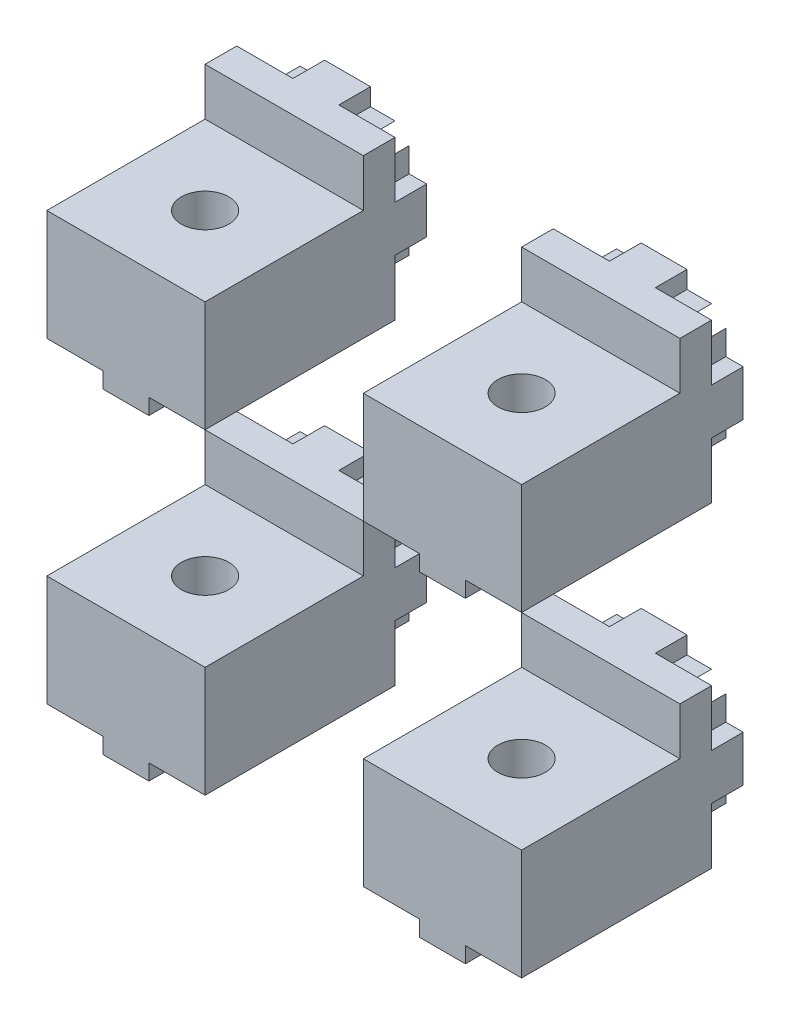
from build123d import *

# Parameters (mm, degrees)
SKETCH1_W                         = 10
SKETCH1_H                         = 10
MAIN_DEPTH                        = 12
ANTIROTATIONSYSTEM_DEPTH          = 2
CIRPATTERN1_COUNT                 = 4
SKETCH3_W                         = 10
SKETCH3_H                         = 10
MAKERBEAMSQUAREHOLEFORSCREW_DEPTH = 3
SKETCH5_W                         = 2.9
SKETCH5_H                         = 12
MAKERBEAMRAIL_DEPTH               = 1
SKETCH4_R                         = 1.5
VERTICALMAKERBEAMHOLE_DEPTH       = 16.264337522
LPATTERN1_COUNT                   = 2
LPATTERN1_PITCH                   = 20
LPATTERN1_2_COUNT                 = 2
LPATTERN1_2_PITCH                 = 20


with BuildPart() as part:
    # Sketch1 → Main (new body)
    with BuildSketch(Plane.XY):
        Rectangle(SKETCH1_W, SKETCH1_H)
    extrude(amount=MAIN_DEPTH)

    # Sketch2 → AntiRotationSystem (add)
    with BuildSketch(Plane(origin=(0, 0, 0), x_dir=(-1, 0, 0), z_dir=(0, 0, -1))):
        Polygon((-5, 1.45), (-3.9, 1.45), (-3.9, 3), (-2.1, 0.95), (-2.1, -0.95), (-3.9, -3), (-3.9, -1.45), (-5, -1.45), align=None)
    antirotationsystem = extrude(amount=ANTIROTATIONSYSTEM_DEPTH)

    # CirPattern1: AntiRotationSystem ×4 about axis
    cirpattern1_axis = Axis((0, 0, -1.2), (0, 0, 1))
    for i in range(1, CIRPATTERN1_COUNT):
        add(antirotationsystem.rotate(cirpattern1_axis, i * 360 / CIRPATTERN1_COUNT))

    # Sketch3 → MakerBeamSquareHoleForScrew (cut)
    with BuildSketch(Plane(origin=(0, 5, 0), x_dir=(1, 0, 0), z_dir=(0, 1, 0))):
        with Locations((0, -7)):
            Rectangle(SKETCH3_W, SKETCH3_H)
    extrude(amount=-MAKERBEAMSQUAREHOLEFORSCREW_DEPTH, mode=Mode.SUBTRACT)

    # Sketch5 → MakerBeamRail (add)
    with BuildSketch(Plane(origin=(0, -5, 0), x_dir=(-1, 0, 0), z_dir=(0, -1, 0))):
        with Locations((0, -6)):
            Rectangle(SKETCH5_W, SKETCH5_H)
    extrude(amount=MAKERBEAMRAIL_DEPTH)

    # Sketch4 → VerticalMakerBeamHole (cut, through all)
    with BuildSketch(Plane(origin=(0, 2, 0), x_dir=(1, 0, 0), z_dir=(0, 1, 0))):
        with Locations((0, -7)):
            Circle(SKETCH4_R)
    extrude(amount=-VERTICALMAKERBEAMHOLE_DEPTH, mode=Mode.SUBTRACT)


with BuildPart() as lpattern1_1:
    # LPattern1: pattern copy
    add(part.part.moved(Location(Vector(-1, 0, 0) * (1 * LPATTERN1_PITCH))))


with BuildPart() as lpattern1_2_1:
    # LPattern1 2: pattern copy
    add(part.part.moved(Location(Vector(0, -1, 0) * (1 * LPATTERN1_2_PITCH))))


with BuildPart() as lpattern1_2_2:
    # LPattern1 2: pattern copy
    add(lpattern1_1.part.moved(Location(Vector(0, -1, 0) * (1 * LPATTERN1_2_PITCH))))


solid = Compound([part.part, lpattern1_1.part, lpattern1_2_1.part, lpattern1_2_2.part])
